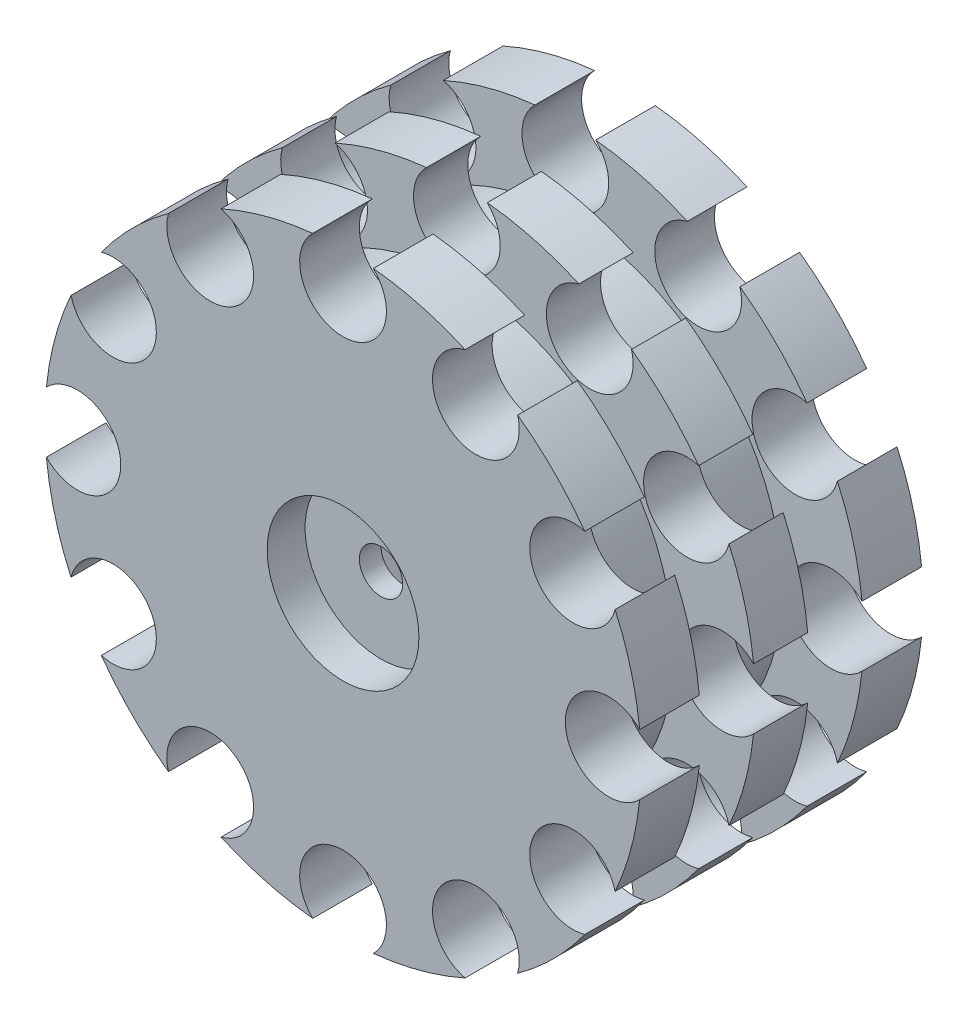
from build123d import *

# Parameters (mm, degrees)
CORTAR_EXTRUIR1_DEPTH = 9
CROQUIS5_R            = 4
CORTAR_EXTRUIR3_DEPTH = 27
CROQUIS6_R            = 2
CORTAR_EXTRUIR4_DEPTH = 10


with BuildPart() as part:
    # Croquis1 → Revolución1 (revolve)
    with BuildSketch(Plane(origin=(0, 0, 0), x_dir=(1, 0, 0), z_dir=(0, 1, 0))):
        Polygon((0, 1.5), (0, -9.5), (7, -9.5), (7, -13), (12.5, -13), (27.5, -13), (27.5, -7.5), (20, -7.5), (20, -2.5), (27.5, -2.5), (27.5, 2.5), (20, 2.5), (20, 7.5), (27.5, 7.5), (27.5, 13), (12.5, 13), (12.5, 6.5), (7.5, 1.5), align=None)
    revolve(axis=Axis((0, 0, 0), (0, 0, -1)))

    # Croquis2 → Cortar-Extruir1 (cut)
    with BuildSketch(Plane(origin=(0, 0, -1.5), x_dir=(-1, 0, 0), z_dir=(0, 0, -1))):
        Polygon((7.505553499, 0), (3.75277675, 6.5), (-3.75277675, 6.5), (-7.505553499, 0), (-3.75277675, -6.5), (3.75277675, -6.5), align=None)
    extrude(amount=-CORTAR_EXTRUIR1_DEPTH, mode=Mode.SUBTRACT)

    # Croquis5 → Cortar-Extruir3 (cut, through all)
    with BuildSketch(Plane.XY.offset(13)):
        with Locations((0, 24.5)):
            Circle(CROQUIS5_R)
        with Locations((12.25, 21.217622393)):
            Circle(CROQUIS5_R)
        with Locations((21.217622393, 12.25)):
            Circle(CROQUIS5_R)
        with Locations((24.5, 0)):
            Circle(CROQUIS5_R)
        with Locations((21.217622393, -12.25)):
            Circle(CROQUIS5_R)
        with Locations((12.25, -21.217622393)):
            Circle(CROQUIS5_R)
        with Locations((0, -24.5)):
            Circle(CROQUIS5_R)
        with Locations((-12.25, -21.217622393)):
            Circle(CROQUIS5_R)
        with Locations((-21.217622393, -12.25)):
            Circle(CROQUIS5_R)
        with Locations((-24.5, 0)):
            Circle(CROQUIS5_R)
        with Locations((-21.217622393, 12.25)):
            Circle(CROQUIS5_R)
        with Locations((-12.25, 21.217622393)):
            Circle(CROQUIS5_R)
    extrude(amount=-CORTAR_EXTRUIR3_DEPTH, mode=Mode.SUBTRACT)

    # Croquis6 → Cortar-Extruir4 (cut)
    with BuildSketch(Plane(origin=(0, 0, 7.5), x_dir=(-1, 0, 0), z_dir=(0, 0, -1))):
        Circle(CROQUIS6_R)
    extrude(amount=-CORTAR_EXTRUIR4_DEPTH, mode=Mode.SUBTRACT)


solid = part.part
